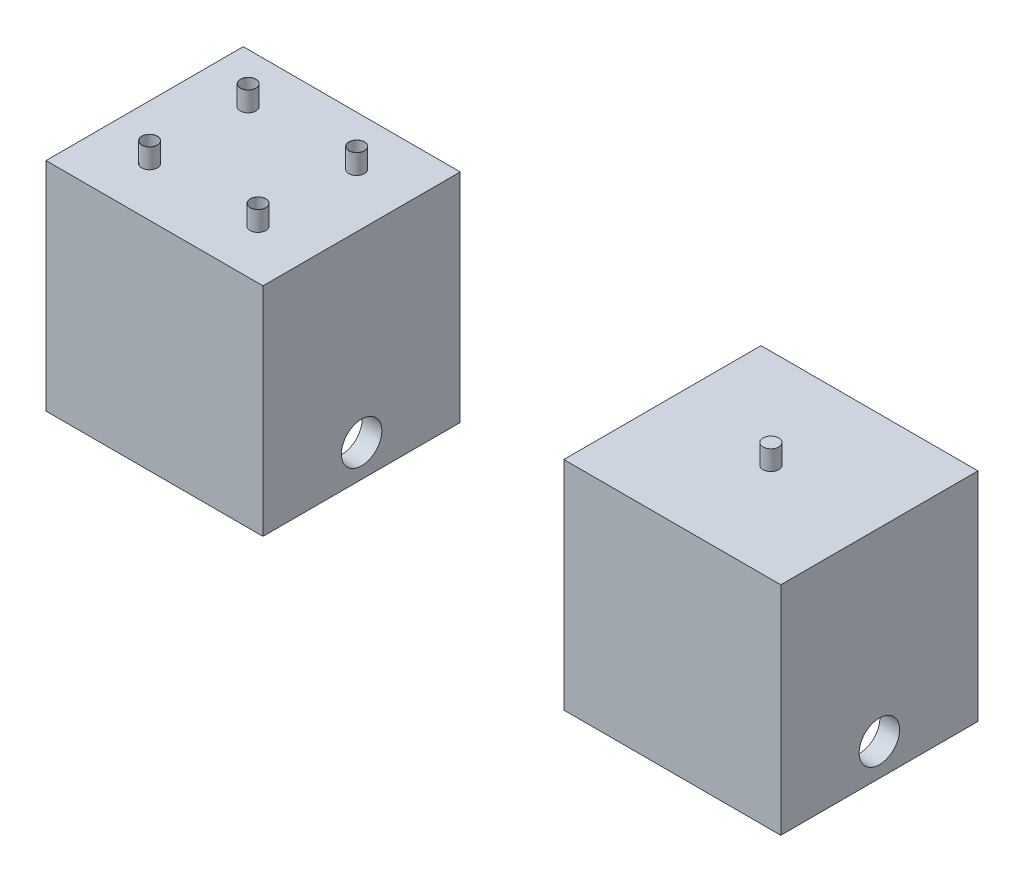
from build123d import *

# Parameters (mm, degrees)
BOSS_EXTRUDE1_DEPTH   = 20
CUT_EXTRUDE2_START    = -22
SKETCH3_W             = 18
SKETCH3_H             = 16
CUT_EXTRUDE2_DEPTH    = 15
SKETCH4_R             = 0.79375
CUT_EXTRUDE3_DEPTH    = 23
SKETCH5_R             = 0.79375
SKETCH5_R_2           = 0.77375
BOSS_EXTRUDE3_DEPTH   = 2
BOSS_EXTRUDE3_2_DEPTH = 2
BOSS_EXTRUDE3_3_DEPTH = 2
BOSS_EXTRUDE3_4_DEPTH = 2
BOSS_EXTRUDE3_5_DEPTH = 2
CUT_EXTRUDE6_START    = 35.25
SKETCH11_R            = 2.05
CUT_EXTRUDE6_DEPTH    = 2
CUT_EXTRUDE7_START    = -37.25
SKETCH11_2_R          = 2.05
CUT_EXTRUDE7_DEPTH    = 2
CUT_EXTRUDE8_START    = -17.25
SKETCH11_3_R          = 2.05
CUT_EXTRUDE8_DEPTH    = 34.5
SKETCH6_R             = 2.05
CUT_EXTRUDE9_DEPTH    = 23
SKETCH12_W            = 30.5
SKETCH12_H            = 20
CUT_EXTRUDE10_DEPTH   = 23


with BuildPart() as part:
    # Sketch1 → Boss-Extrude1 (new body)
    with BuildSketch(Plane.XY):
        Polygon((37.25, 0), (-37.25, 0), (-37.25, -22), (-15.25, -22), (-15.25, -5), (15.25, -5), (15.25, -22), (37.25, -22), align=None)
    extrude(amount=BOSS_EXTRUDE1_DEPTH)

    # Sketch3 → Cut-Extrude2 (cut)
    with BuildSketch(Plane(origin=(0, 0, 0), x_dir=(1, 0, 0), z_dir=(0, 1, 0)).offset(CUT_EXTRUDE2_START)):
        with Locations((-26.25, -10)):
            Rectangle(SKETCH3_W, SKETCH3_H)
        with Locations((26.25, -10)):
            Rectangle(SKETCH3_W, SKETCH3_H)
    extrude(amount=CUT_EXTRUDE2_DEPTH, mode=Mode.SUBTRACT)

    # Sketch4 → Cut-Extrude3 (cut, through all)
    with BuildSketch(Plane(origin=(0, 0, 0), x_dir=(1, 0, 0), z_dir=(0, 1, 0))):
        with Locations((-31.75, -5)):
            Circle(SKETCH4_R)
        with Locations((-20.75, -5)):
            Circle(SKETCH4_R)
        with Locations((-20.75, -15)):
            Circle(SKETCH4_R)
        with Locations((-31.75, -15)):
            Circle(SKETCH4_R)
        with Locations((26.25, -10)):
            Circle(SKETCH4_R)
    extrude(amount=-CUT_EXTRUDE3_DEPTH, mode=Mode.SUBTRACT)

    # Sketch11 → Cut-Extrude6 (cut)
    with BuildSketch(Plane(origin=(0, 0, 0), x_dir=(0, 0, -1), z_dir=(1, 0, 0)).offset(CUT_EXTRUDE6_START)):
        with Locations((-10, -18.75)):
            Circle(SKETCH11_R)
    extrude(amount=CUT_EXTRUDE6_DEPTH, mode=Mode.SUBTRACT)

    # Sketch11_2 → Cut-Extrude7 (cut)
    with BuildSketch(Plane(origin=(0, 0, 0), x_dir=(0, 0, -1), z_dir=(1, 0, 0)).offset(CUT_EXTRUDE7_START)):
        with Locations((-10, -18.75)):
            Circle(SKETCH11_2_R)
    extrude(amount=CUT_EXTRUDE7_DEPTH, mode=Mode.SUBTRACT)

    # Sketch11_3 → Cut-Extrude8 (cut)
    with BuildSketch(Plane(origin=(0, 0, 0), x_dir=(0, 0, -1), z_dir=(1, 0, 0)).offset(CUT_EXTRUDE8_START)):
        with Locations((-10, -18.75)):
            Circle(SKETCH11_3_R)
    extrude(amount=CUT_EXTRUDE8_DEPTH, mode=Mode.SUBTRACT)

    # Sketch6 → Cut-Extrude9 (cut, through all)
    with BuildSketch(Plane(origin=(0, 0, 0), x_dir=(1, 0, 0), z_dir=(0, 1, 0))):
        with Locations((0, -10)):
            Circle(SKETCH6_R)
    extrude(amount=-CUT_EXTRUDE9_DEPTH, mode=Mode.SUBTRACT)

    # Sketch12 → Cut-Extrude10 (cut, through all)
    with BuildSketch(Plane(origin=(0, 0, 0), x_dir=(1, 0, 0), z_dir=(0, 1, 0))):
        with Locations((0, -10)):
            Rectangle(SKETCH12_W, SKETCH12_H)
    extrude(amount=-CUT_EXTRUDE10_DEPTH, mode=Mode.SUBTRACT)


with BuildPart() as body_2:
    # Sketch5 → Boss-Extrude3 (new body)
    with BuildSketch(Plane(origin=(0, 0, 0), x_dir=(1, 0, 0), z_dir=(0, 1, 0))):
        with Locations((-31.75, -5)):
            Circle(SKETCH5_R)
        with Locations((-31.75, -5)):
            Circle(SKETCH5_R_2, mode=Mode.SUBTRACT)
    extrude(amount=BOSS_EXTRUDE3_DEPTH)


with BuildPart() as body_3:
    # Sketch5 → Boss-Extrude3 2 (new body)
    with BuildSketch(Plane(origin=(0, 0, 0), x_dir=(1, 0, 0), z_dir=(0, 1, 0))):
        with Locations((-20.75, -5)):
            Circle(SKETCH5_R)
        with Locations((-20.75, -5)):
            Circle(SKETCH5_R_2, mode=Mode.SUBTRACT)
    extrude(amount=BOSS_EXTRUDE3_2_DEPTH)


with BuildPart() as body_4:
    # Sketch5 → Boss-Extrude3 3 (new body)
    with BuildSketch(Plane(origin=(0, 0, 0), x_dir=(1, 0, 0), z_dir=(0, 1, 0))):
        with Locations((-20.75, -15)):
            Circle(SKETCH5_R)
        with Locations((-20.75, -15)):
            Circle(SKETCH5_R_2, mode=Mode.SUBTRACT)
    extrude(amount=BOSS_EXTRUDE3_3_DEPTH)


with BuildPart() as body_5:
    # Sketch5 → Boss-Extrude3 4 (new body)
    with BuildSketch(Plane(origin=(0, 0, 0), x_dir=(1, 0, 0), z_dir=(0, 1, 0))):
        with Locations((-31.75, -15)):
            Circle(SKETCH5_R)
        with Locations((-31.75, -15)):
            Circle(SKETCH5_R_2, mode=Mode.SUBTRACT)
    extrude(amount=BOSS_EXTRUDE3_4_DEPTH)


with BuildPart() as body_6:
    # Sketch5 → Boss-Extrude3 5 (new body)
    with BuildSketch(Plane(origin=(0, 0, 0), x_dir=(1, 0, 0), z_dir=(0, 1, 0))):
        with Locations((26.25, -10)):
            Circle(SKETCH5_R)
    extrude(amount=BOSS_EXTRUDE3_5_DEPTH)


solid = Compound([part.part, body_2.part, body_3.part, body_4.part, body_5.part, body_6.part])
